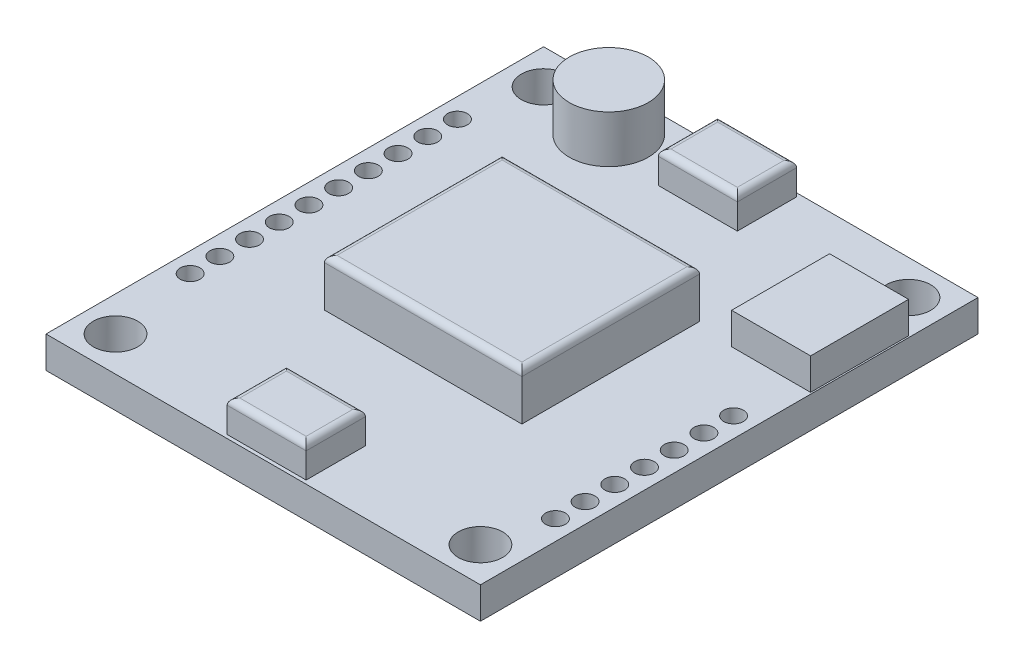
from build123d import *

# Parameters (mm, degrees)
SKETCH1_W                           = 34.925
SKETCH1_H                           = 40
BOSS_EXTRUDE1_DEPTH                 = 2.54
F_9_64_0_14063_DIAMETER_HOLE1_D     = 3.572002
F_9_64_0_14063_DIAMETER_HOLE1_DEPTH = 2.54
F_1_16_0_0625_DIAMETER_HOLE1_D      = 1.5875
F_1_16_0_0625_DIAMETER_HOLE1_DEPTH  = 2.54
SKETCH6_R                           = 3.175
BOSS_EXTRUDE2_DEPTH                 = 3.81
SKETCH7_W                           = 15.875
SKETCH7_H                           = 14.2875
BOSS_EXTRUDE3_DEPTH                 = 3.81
FILLET1_R                           = 0.508
SKETCH8_W                           = 6.35
SKETCH8_H                           = 7.874
BOSS_EXTRUDE4_DEPTH                 = 2.54
SKETCH10_W                          = 6.35
SKETCH10_H                          = 4.7625
BOSS_EXTRUDE5_DEPTH                 = 2.54
FILLET2_R                           = 0.508


with BuildPart() as part:
    # Sketch1 → Boss-Extrude1 (new body)
    with BuildSketch(Plane(origin=(0, 0, 0), x_dir=(1, 0, 0), z_dir=(0, 1, 0))):
        Rectangle(SKETCH1_W, SKETCH1_H)
    extrude(amount=BOSS_EXTRUDE1_DEPTH)

    # 9/64 (0.14063) Diameter Hole1
    with Locations(Plane(origin=(0, 2.54, 0), x_dir=(1, 0, 0), z_dir=(0, 1, 0))):
        with Locations((-14.6685, 17.206), (14.6685, 17.206), (14.6685, -17.206), (-14.6685, -17.206)):
            Hole(F_9_64_0_14063_DIAMETER_HOLE1_D / 2, depth=F_9_64_0_14063_DIAMETER_HOLE1_DEPTH)

    # 1/16 (0.0625) Diameter Hole1
    with Locations(Plane(origin=(0, 2.54, 0), x_dir=(1, 0, 0), z_dir=(0, 1, 0))):
        with Locations((-15.875, -10), (-15.875, -7.6124), (-15.875, -5.2248), (-15.875, -2.8372), (-15.875, -0.4496), (-15.875, 1.938), (-15.875, 4.3256), (-15.875, 6.7132), (-15.875, 9.1008), (-15.875, 11.4884), (15.875, 1.938), (15.875, -0.4496), (15.875, -2.8372), (15.875, -5.2248), (15.875, -7.6124), (15.875, -10), (15.875, -12.38125)):
            Hole(F_1_16_0_0625_DIAMETER_HOLE1_D / 2, depth=F_1_16_0_0625_DIAMETER_HOLE1_DEPTH)

    # Sketch6 → Boss-Extrude2 (add)
    with BuildSketch(Plane(origin=(0, 2.54, 0), x_dir=(1, 0, 0), z_dir=(0, 1, 0))):
        with Locations((-8.73125, 16.5125)):
            Circle(SKETCH6_R)
    extrude(amount=BOSS_EXTRUDE2_DEPTH)

    # Sketch7 → Boss-Extrude3 (add)
    with BuildSketch(Plane(origin=(0, 2.54, 0), x_dir=(1, 0, 0), z_dir=(0, 1, 0))):
        Rectangle(SKETCH7_W, SKETCH7_H)
    extrude(amount=BOSS_EXTRUDE3_DEPTH)

    # Fillet1
    fillet1_edges = [part.edges().sort_by_distance(p)[0] for p in [
        (7.9375, 6.35, 0),
        (0, 6.35, -7.14375),
        (-7.9375, 6.35, 0),
        (0, 6.35, 7.14375),
    ]]
    fillet(fillet1_edges, radius=FILLET1_R)

    # Sketch8 → Boss-Extrude4 (add)
    with BuildSketch(Plane(origin=(0, 2.54, 0), x_dir=(1, 0, 0), z_dir=(0, 1, 0))):
        with Locations((14.1605, 10.607)):
            Rectangle(SKETCH8_W, SKETCH8_H)
    extrude(amount=BOSS_EXTRUDE4_DEPTH)

    # Sketch10 → Boss-Extrude5 (add)
    with BuildSketch(Plane(origin=(0, 2.54, 0), x_dir=(1, 0, 0), z_dir=(0, 1, 0))):
        with Locations((-0.010133196, 17.333)):
            Rectangle(SKETCH10_W, SKETCH10_H)
        with Locations((-0.010133196, -17.333)):
            Rectangle(SKETCH10_W, SKETCH10_H)
    extrude(amount=BOSS_EXTRUDE5_DEPTH)

    # Fillet2
    fillet2_edges = [part.edges().sort_by_distance(p)[0] for p in [
        (-3.185133196, 5.08, -17.333),
        (-0.010133196, 5.08, -14.95175),
        (3.164866804, 5.08, -17.333),
        (-0.010133196, 5.08, -19.71425),
        (3.164866804, 5.08, 17.333),
        (-0.010133196, 5.08, 14.95175),
        (-3.185133196, 5.08, 17.333),
        (-0.010133196, 5.08, 19.71425),
    ]]
    fillet(fillet2_edges, radius=FILLET2_R)


solid = part.part
